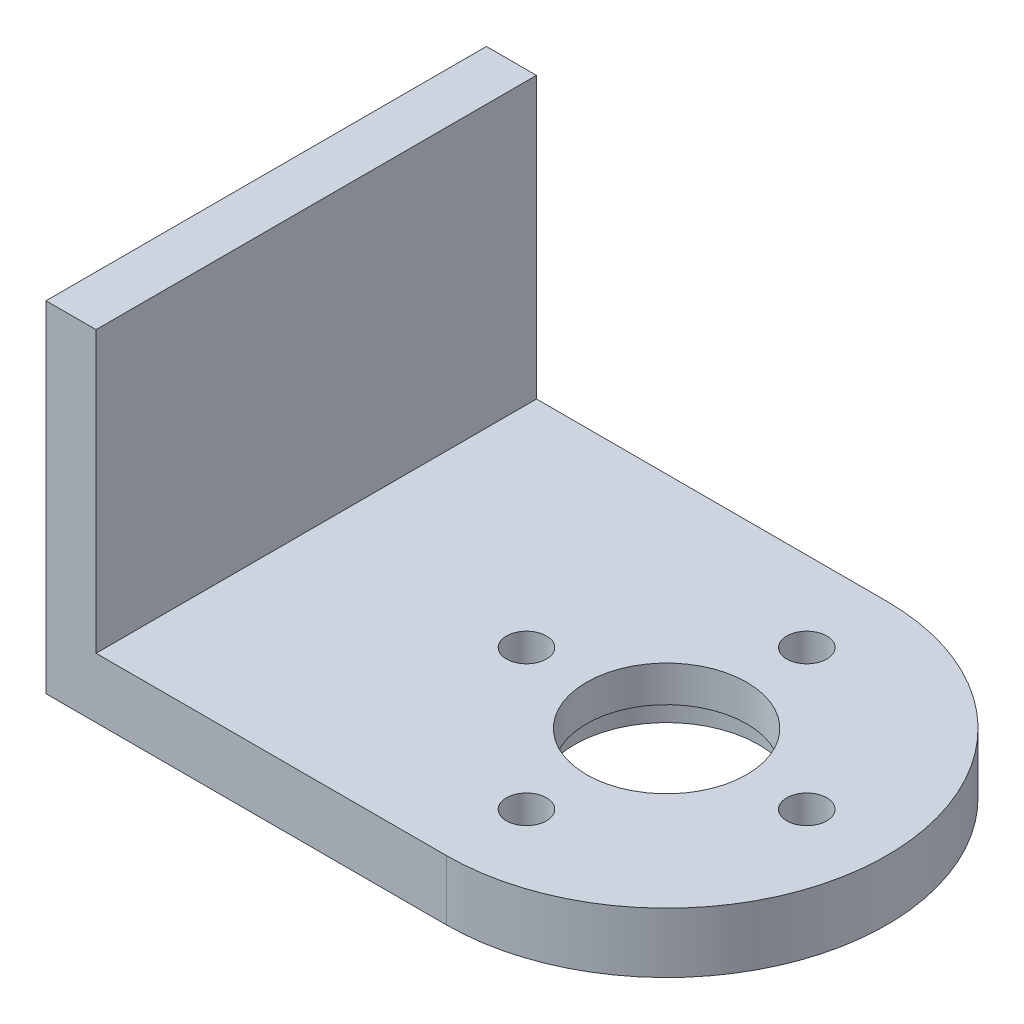
from build123d import *

# Parameters (mm, degrees)
SKETCH1_R           = 1
SKETCH1_R_2         = 4
BOSS_EXTRUDE1_DEPTH = 3
SKETCH2_W           = 2.5
SKETCH2_H           = 22
BOSS_EXTRUDE2_DEPTH = 14
SKETCH4_R           = 4.6
CUT_EXTRUDE2_DEPTH  = 1.2
SKETCH5_R           = 1.9
CUT_EXTRUDE3_DEPTH  = 1.5


with BuildPart() as part:
    # Sketch1 → Boss-Extrude1 (new body)
    with BuildSketch(Plane(origin=(0, 0, 0), x_dir=(1, 0, 0), z_dir=(0, 1, 0))):
        with BuildLine():
            Line((-14, -11), (-14, 11))
            Line((-14, 11), (6, 11))
            ThreePointArc((6, 11), (17, 0), (6, -11))
            Line((6, -11), (-14, -11))
        make_face()
        with Locations((6, -7)):
            Circle(SKETCH1_R, mode=Mode.SUBTRACT)
        with Locations((-1, 0)):
            Circle(SKETCH1_R, mode=Mode.SUBTRACT)
        with Locations((6, 0)):
            Circle(SKETCH1_R_2, mode=Mode.SUBTRACT)
        with Locations((13, 0)):
            Circle(SKETCH1_R, mode=Mode.SUBTRACT)
        with Locations((6, 7)):
            Circle(SKETCH1_R, mode=Mode.SUBTRACT)
    extrude(amount=BOSS_EXTRUDE1_DEPTH)

    # Sketch2 → Boss-Extrude2 (add)
    with BuildSketch(Plane(origin=(0, 3, 0), x_dir=(1, 0, 0), z_dir=(0, 1, 0))):
        with Locations((-12.75, 0)):
            Rectangle(SKETCH2_W, SKETCH2_H)
    extrude(amount=BOSS_EXTRUDE2_DEPTH)

    # Sketch4 → Cut-Extrude2 (cut)
    with BuildSketch(Plane.XZ):
        with Locations((6, 0)):
            Circle(SKETCH4_R)
    extrude(amount=-CUT_EXTRUDE2_DEPTH, mode=Mode.SUBTRACT)

    # Sketch5 → Cut-Extrude3 (cut)
    with BuildSketch(Plane.XZ):
        with Locations((13, 0)):
            Circle(SKETCH5_R)
        with Locations((6, -7)):
            Circle(SKETCH5_R)
        with Locations((-1, 0)):
            Circle(SKETCH5_R)
        with Locations((6, 7)):
            Circle(SKETCH5_R)
    extrude(amount=-CUT_EXTRUDE3_DEPTH, mode=Mode.SUBTRACT)


solid = part.part
